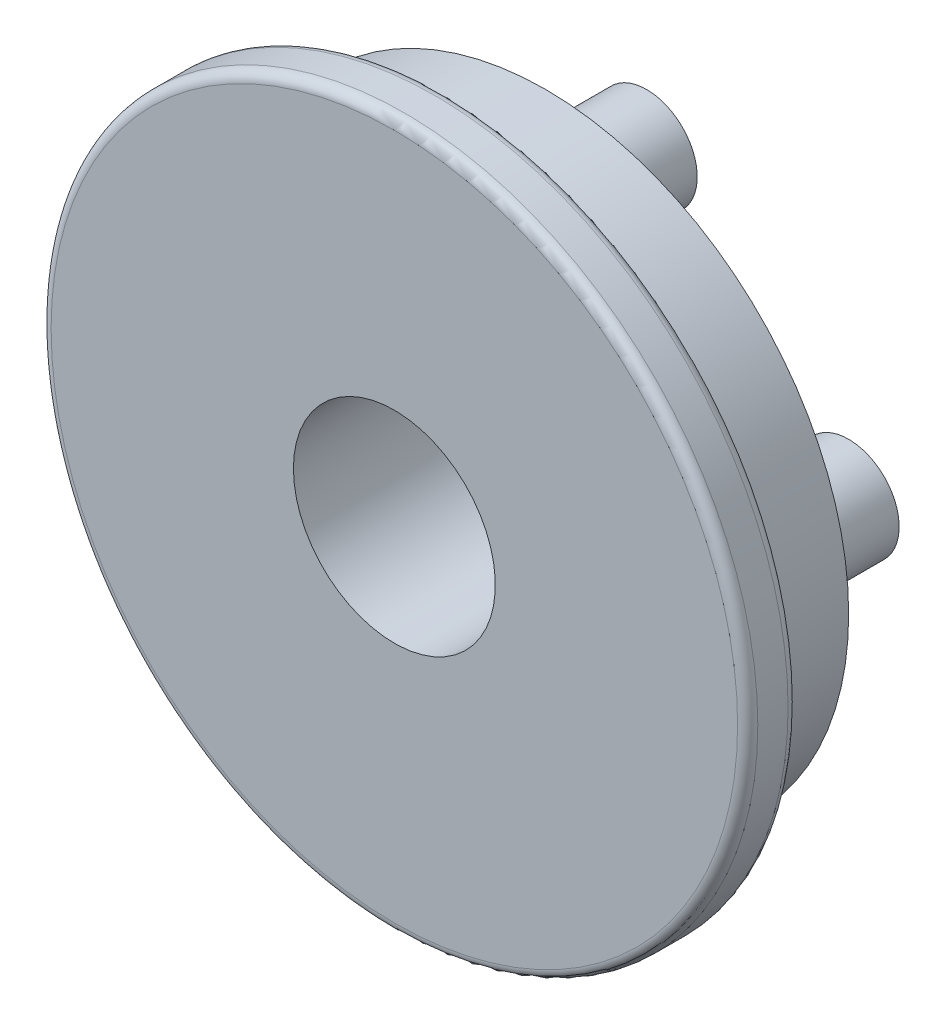
from build123d import *

# Parameters (mm, degrees)
SKETCH1_R           = 35
BOSS_EXTRUDE1_DEPTH = 5
FILLET1_R           = 1
SKETCH2_R           = 30
BOSS_EXTRUDE2_DEPTH = 10
SKETCH3_R           = 5
BOSS_EXTRUDE3_DEPTH = 10
SKETCH4_R           = 10
CUT_EXTRUDE1_DEPTH  = 16


with BuildPart() as part:
    # Sketch1 → Boss-Extrude1 (new body)
    with BuildSketch(Plane.XY):
        Circle(SKETCH1_R)
    extrude(amount=BOSS_EXTRUDE1_DEPTH)

    # Fillet1
    fillet1_edges = [part.edges().sort_by_distance(p)[0] for p in [
        (-35, 0, 0),
        (-35, 0, 5),
    ]]
    fillet(fillet1_edges, radius=FILLET1_R)

    # Sketch2 → Boss-Extrude2 (add)
    with BuildSketch(Plane(origin=(0, 0, 0), x_dir=(-1, 0, 0), z_dir=(0, 0, -1))):
        Circle(SKETCH2_R)
    extrude(amount=BOSS_EXTRUDE2_DEPTH)

    # Sketch3 → Boss-Extrude3 (add)
    with BuildSketch(Plane(origin=(0, 0, -10), x_dir=(-1, 0, 0), z_dir=(0, 0, -1))):
        with Locations((0, 20)):
            Circle(SKETCH3_R)
        with Locations((20, 0)):
            Circle(SKETCH3_R)
        with Locations((0, -20)):
            Circle(SKETCH3_R)
        with Locations((-20, 0)):
            Circle(SKETCH3_R)
    extrude(amount=BOSS_EXTRUDE3_DEPTH)

    # Sketch4 → Cut-Extrude1 (cut, through all)
    with BuildSketch(Plane(origin=(0, 0, -10), x_dir=(-1, 0, 0), z_dir=(0, 0, -1))):
        Circle(SKETCH4_R)
    extrude(amount=-CUT_EXTRUDE1_DEPTH, mode=Mode.SUBTRACT)


solid = part.part
